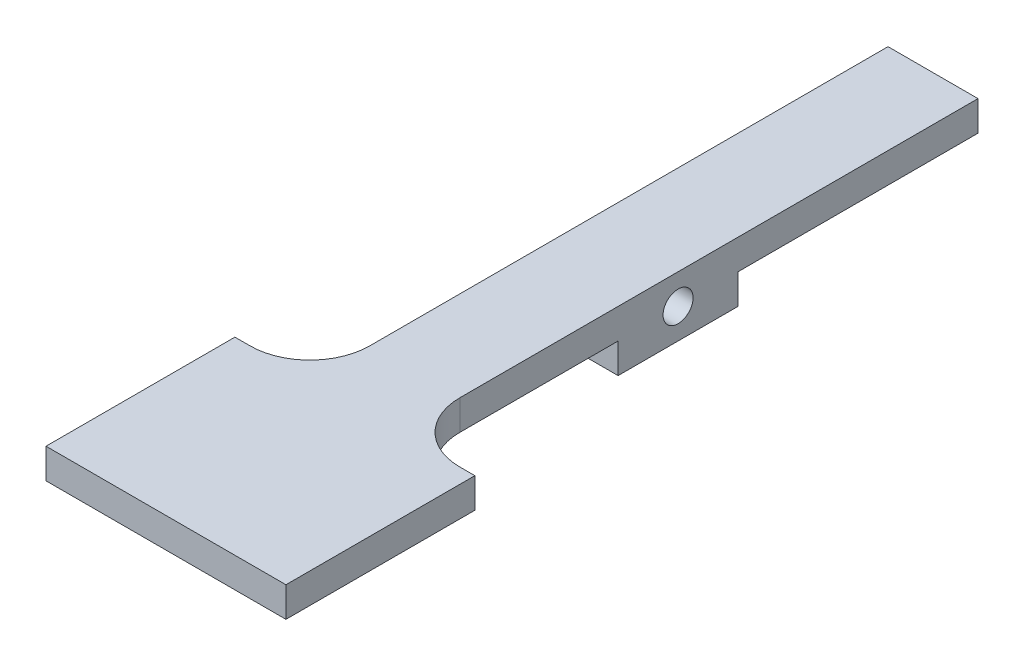
from build123d import *

# Parameters (mm, degrees)
SKETCH1_R           = 1.5875
BOSS_EXTRUDE1_DEPTH = 9.525
SKETCH3_W           = 15
SKETCH3_H           = 3.175
SKETCH3_W_2         = 5
BOSS_EXTRUDE2_DEPTH = 12.7
FILLET1_R           = 6.35


with BuildPart() as part:
    # Sketch1 → Boss-Extrude1 (new body)
    with BuildSketch(Plane(origin=(0, 0, 0), x_dir=(0, 0, -1), z_dir=(1, 0, 0))):
        Polygon((0, 1.5875), (0, -1.5875), (-25.4, -1.5875), (-25.4, -4.7625), (-38.1, -4.7625), (-38.1, -1.5875), (-76.2, -1.5875), (-76.2, 1.5875), align=None)
        with Locations((-31.75, -1.5875)):
            Circle(SKETCH1_R, mode=Mode.SUBTRACT)
    extrude(amount=BOSS_EXTRUDE1_DEPTH)

    # Sketch3 → Boss-Extrude2 (add, symmetric)
    with BuildSketch(Plane(origin=(4.7625, 0, 0), x_dir=(0, 0, -1), z_dir=(1, 0, 0))):
        with Locations((-68.7, 0)):
            Rectangle(SKETCH3_W, SKETCH3_H)
        with Locations((-78.7, 0)):
            Rectangle(SKETCH3_W_2, SKETCH3_H)
    extrude(amount=BOSS_EXTRUDE2_DEPTH, both=True)

    # Fillet1
    fillet1_edges = [part.edges().sort_by_distance(p)[0] for p in [
        (0, 0, 61.2),
        (9.525, 0, 61.2),
    ]]
    fillet(fillet1_edges, radius=FILLET1_R)


solid = part.part
